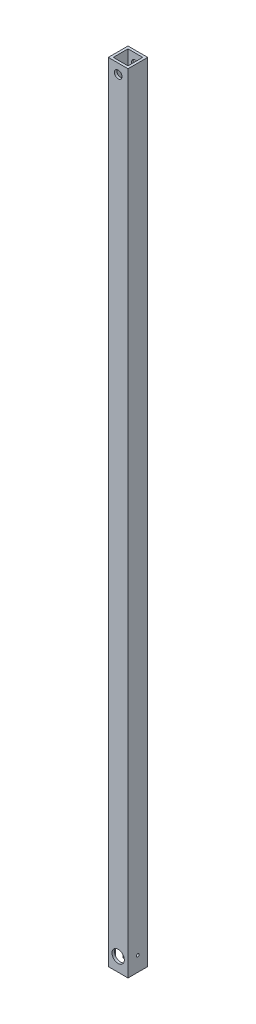
from build123d import *

# Parameters (mm, degrees)
SKETCH1_W               = 12.7
SKETCH1_H               = 12.7
SKETCH1_W_2             = 9.525
SKETCH1_H_2             = 9.525
EXTRUDE_THIN1_DEPTH     = 508
SKETCH2_R               = 3.96875
CUT_EXTRUDE1_DEPTH      = 1.5875
SKETCH3_R               = 2.4765
CUT_EXTRUDE2_DEPTH      = 1
CUT_EXTRUDE2_DEPTH_BACK = 13.7
CUT_EXTRUDE3_REACH      = 14.7
SKETCH4_R               = 0.889
CUT_EXTRUDE4_REACH      = 14.7
SKETCH5_W               = 6.35
SKETCH5_H               = 9.525


with BuildPart() as part:
    # Sketch1 → Extrude-Thin1 (new body)
    with BuildSketch(Plane(origin=(0, 0, 0), x_dir=(1, 0, 0), z_dir=(0, 1, 0))):
        Rectangle(SKETCH1_W, SKETCH1_H)
        Rectangle(SKETCH1_W_2, SKETCH1_H_2, mode=Mode.SUBTRACT)
    extrude(amount=EXTRUDE_THIN1_DEPTH)

    # Sketch2 → Cut-Extrude1 (cut)
    with BuildSketch(Plane.XY.offset(6.35)):
        with Locations((0, 8.9123012)):
            Circle(SKETCH2_R)
    extrude(amount=-CUT_EXTRUDE1_DEPTH, mode=Mode.SUBTRACT)

    # Sketch3 → Cut-Extrude2 (cut, two sides)
    with BuildSketch(Plane.XY.offset(6.35)) as cut_extrude2_sk:
        with Locations((0, 501.65)):
            Circle(SKETCH3_R)
    extrude(amount=CUT_EXTRUDE2_DEPTH, mode=Mode.SUBTRACT)
    extrude(cut_extrude2_sk.sketch, amount=-CUT_EXTRUDE2_DEPTH_BACK, mode=Mode.SUBTRACT)

    # Sketch4 → Cut-Extrude3 (cut, up to next)
    with BuildSketch(Plane(origin=(6.35, 0, 0), x_dir=(0, 0, -1), z_dir=(1, 0, 0)), mode=Mode.PRIVATE) as cut_extrude3_sk1:
        with Locations((0, 9.525)):
            Circle(SKETCH4_R)
    cut_extrude3_tool1 = extrude(cut_extrude3_sk1.sketch, amount=-CUT_EXTRUDE3_REACH, mode=Mode.PRIVATE) & part.part
    add(cut_extrude3_tool1.solids().sort_by_distance((6.35, 9.525, 0))[0], mode=Mode.SUBTRACT)

    # Sketch5 → Cut-Extrude4 (cut, up to next)
    with BuildSketch(Plane.ZY.offset(6.35), mode=Mode.PRIVATE) as cut_extrude4_sk1:
        with Locations((0, 4.7625)):
            Rectangle(SKETCH5_W, SKETCH5_H)
    cut_extrude4_tool1 = extrude(cut_extrude4_sk1.sketch, amount=-CUT_EXTRUDE4_REACH, mode=Mode.PRIVATE) & part.part
    add(cut_extrude4_tool1.solids().sort_by_distance((-6.35, 4.7625, 0))[0], mode=Mode.SUBTRACT)


solid = part.part
